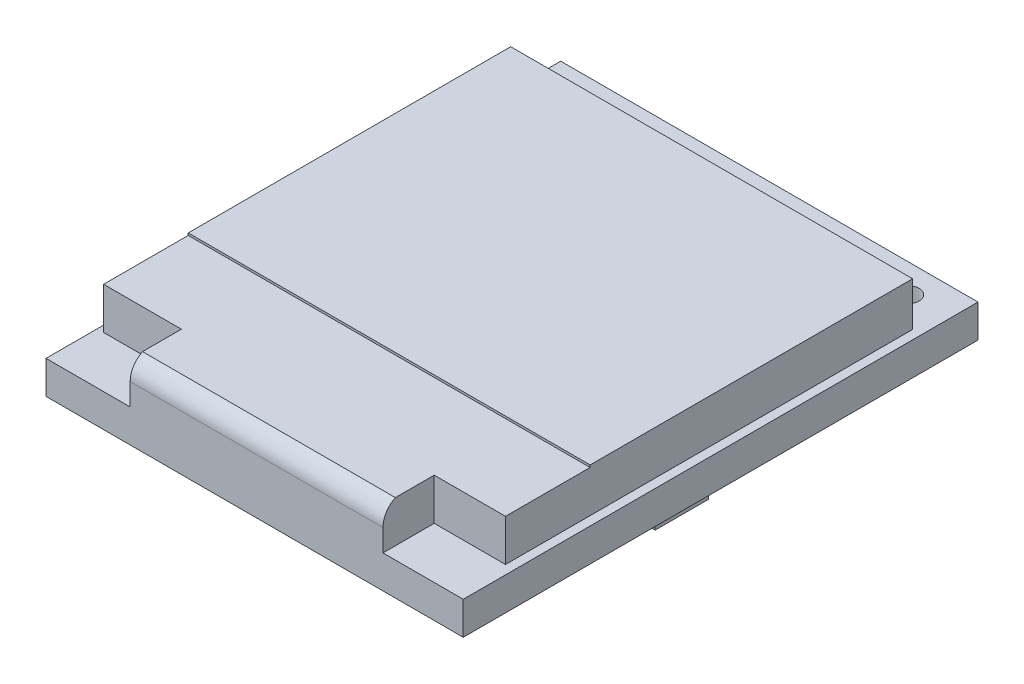
from build123d import *

# Parameters (mm, degrees)
SKETCH1_W           = 19
SKETCH1_H           = 23.44
SKETCH1_R           = 0.5
BOSS_EXTRUDE1_DEPTH = 1.5
BOSS_EXTRUDE2_DEPTH = 2
FILLET1_R           = 1
SKETCH4_W           = 2.923966861
SKETCH4_H           = 2.115382352
BOSS_EXTRUDE3_DEPTH = 1
SKETCH5_W           = 0.965682683
SKETCH5_H           = 2.442516719
BOSS_EXTRUDE4_DEPTH = 0.75
CUT_EXTRUDE1_DEPTH  = 0.1


with BuildPart() as part:
    # Sketch1 → Boss-Extrude1 (new body)
    with BuildSketch(Plane(origin=(0, 0, 0), x_dir=(1, 0, 0), z_dir=(0, 1, 0))):
        with Locations((9.5, -11.72)):
            Rectangle(SKETCH1_W, SKETCH1_H)
        with Locations((1.88, -1.3)):
            Circle(SKETCH1_R, mode=Mode.SUBTRACT)
        with Locations((4.42, -1.3)):
            Circle(SKETCH1_R, mode=Mode.SUBTRACT)
        with Locations((6.96, -1.3)):
            Circle(SKETCH1_R, mode=Mode.SUBTRACT)
        with Locations((9.5, -1.3)):
            Circle(SKETCH1_R, mode=Mode.SUBTRACT)
        with Locations((12.04, -1.3)):
            Circle(SKETCH1_R, mode=Mode.SUBTRACT)
        with Locations((14.58, -1.3)):
            Circle(SKETCH1_R, mode=Mode.SUBTRACT)
        with Locations((17.12, -1.3)):
            Circle(SKETCH1_R, mode=Mode.SUBTRACT)
    extrude(amount=BOSS_EXTRUDE1_DEPTH)

    # Sketch3 → Boss-Extrude2 (add)
    with BuildSketch(Plane(origin=(0, 1.5, 0), x_dir=(1, 0, 0), z_dir=(0, 1, 0))):
        Polygon((3.832385917, -21.106985825), (3.832385917, -23.44), (15.344727023, -23.44), (15.344727023, -21.106985825), (18.591797592, -21.106985825), (18.591797592, -2.569164761), (0.290127115, -2.569164761), (0.290127115, -21.106985825), align=None)
    extrude(amount=BOSS_EXTRUDE2_DEPTH)

    # Fillet1
    fillet1_edges = [part.edges().sort_by_distance(p)[0] for p in [
        (9.58855647, 3.5, 23.44),
    ]]
    fillet(fillet1_edges, radius=FILLET1_R)

    # Sketch4 → Boss-Extrude3 (add)
    with BuildSketch(Plane.XZ):
        with Locations((5.157821851, 8.205990998)):
            Rectangle(SKETCH4_W, SKETCH4_H)
    extrude(amount=BOSS_EXTRUDE3_DEPTH)

    # Sketch5 → Boss-Extrude4 (add)
    with BuildSketch(Plane.XZ):
        with Locations((2.511251492, 12.877880521)):
            Rectangle(SKETCH5_W, SKETCH5_H)
        with Locations((0.971251492, 12.877880521)):
            Rectangle(SKETCH5_W, SKETCH5_H)
        with Locations((4.051251492, 12.877880521)):
            Rectangle(SKETCH5_W, SKETCH5_H)
        with Locations((5.591251492, 12.877880521)):
            Rectangle(SKETCH5_W, SKETCH5_H)
        with Locations((7.131251492, 12.877880521)):
            Rectangle(SKETCH5_W, SKETCH5_H)
        with Locations((10.211251492, 12.877880521)):
            Rectangle(SKETCH5_W, SKETCH5_H)
        with Locations((11.751251491, 12.877880521)):
            Rectangle(SKETCH5_W, SKETCH5_H)
        with Locations((14.831251492, 12.877880521)):
            Rectangle(SKETCH5_W, SKETCH5_H)
        with Locations((16.371251492, 12.877880521)):
            Rectangle(SKETCH5_W, SKETCH5_H)
        with Locations((17.911251492, 12.877880521)):
            Rectangle(SKETCH5_W, SKETCH5_H)
        with Locations((2.511251492, 8.277880522)):
            Rectangle(SKETCH5_W, SKETCH5_H)
    extrude(amount=BOSS_EXTRUDE4_DEPTH)

    # Sketch6 → Cut-Extrude1 (cut)
    with BuildSketch(Plane(origin=(0, 3.5, 0), x_dir=(1, 0, 0), z_dir=(0, 1, 0))):
        Polygon((0.290127115, -17.253788657), (18.591797592, -17.253788657), (18.591797592, -21.106985825), (15.344727023, -21.106985825), (15.344727023, -23.44), (3.832385917, -23.44), (3.832385917, -21.106985825), (0.290127115, -21.106985825), align=None)
    extrude(amount=-CUT_EXTRUDE1_DEPTH, mode=Mode.SUBTRACT)


solid = part.part
